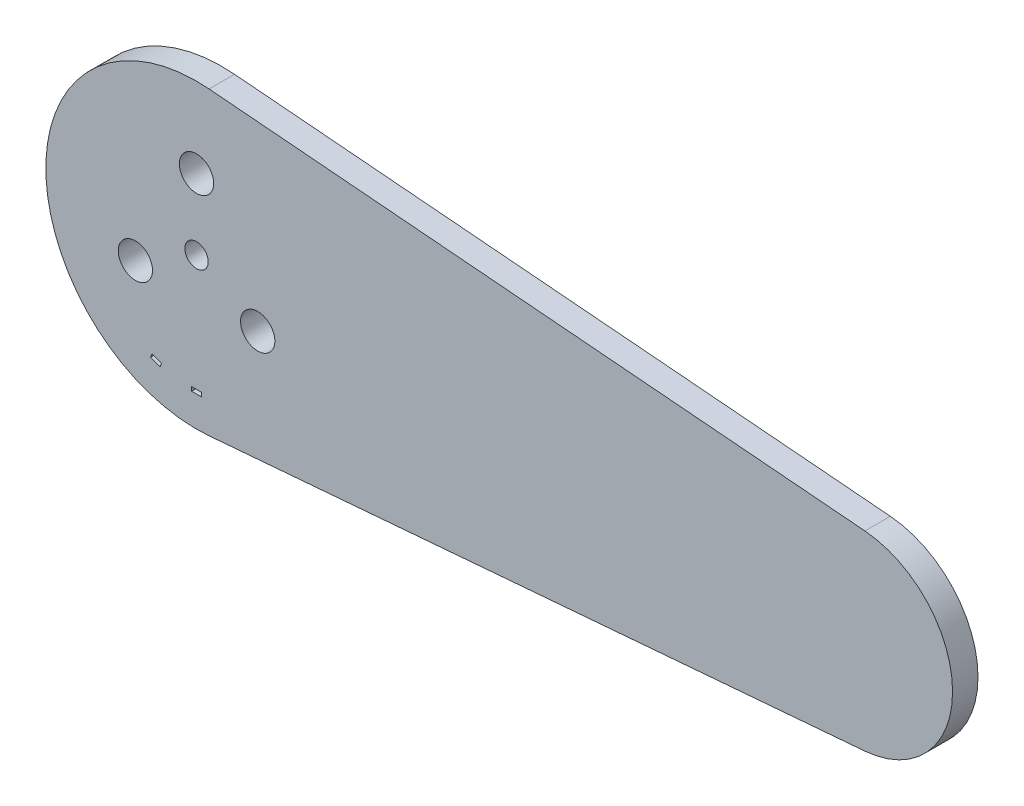
from build123d import *

# Parameters (mm, degrees)
SKETCH1_R           = 1.4732
BOSS_EXTRUDE1_DEPTH = 3.2004
SKETCH2_W           = 1.27
SKETCH2_H           = 0.508
CUT_EXTRUDE1_DEPTH  = 3.2004
SKETCH3_R           = 2.159
CUT_EXTRUDE2_DEPTH  = 3.2004


with BuildPart() as part:
    # Sketch1 → Boss-Extrude1 (new body)
    with BuildSketch(Plane.XY):
        with BuildLine():
            Line((1.58185229, 18.90776), (84.13185229, 12.0015))
            ThreePointArc((84.13185229, 12.0015), (95.171215867, 0), (84.13185229, -12.0015))
            Line((84.13185229, -12.0015), (1.58185229, -18.90776))
            ThreePointArc((1.58185229, -18.90776), (-18.973814716, 0), (1.58185229, 18.90776))
        make_face()
        Circle(SKETCH1_R, mode=Mode.SUBTRACT)
    extrude(amount=BOSS_EXTRUDE1_DEPTH)

    # Sketch2 → Cut-Extrude1 (cut)
    with BuildSketch(Plane.XY.offset(3.2004)):
        Polygon((-4.582879775, -14.447974492), (-4.409133542, -13.970610641), (-5.602543171, -13.536245059), (-5.776289403, -14.01360891), align=None)
        with Locations((0, -14.890092213)):
            Rectangle(SKETCH2_W, SKETCH2_H)
    extrude(amount=-CUT_EXTRUDE1_DEPTH, mode=Mode.SUBTRACT)

    # Sketch3 → Cut-Extrude2 (cut)
    with BuildSketch(Plane.XY.offset(3.2004)):
        with Locations((0, 8.89)):
            Circle(SKETCH3_R)
        with Locations((7.69896584, -4.445)):
            Circle(SKETCH3_R)
        with Locations((-7.69896584, -4.445)):
            Circle(SKETCH3_R)
    extrude(amount=-CUT_EXTRUDE2_DEPTH, mode=Mode.SUBTRACT)


solid = part.part
